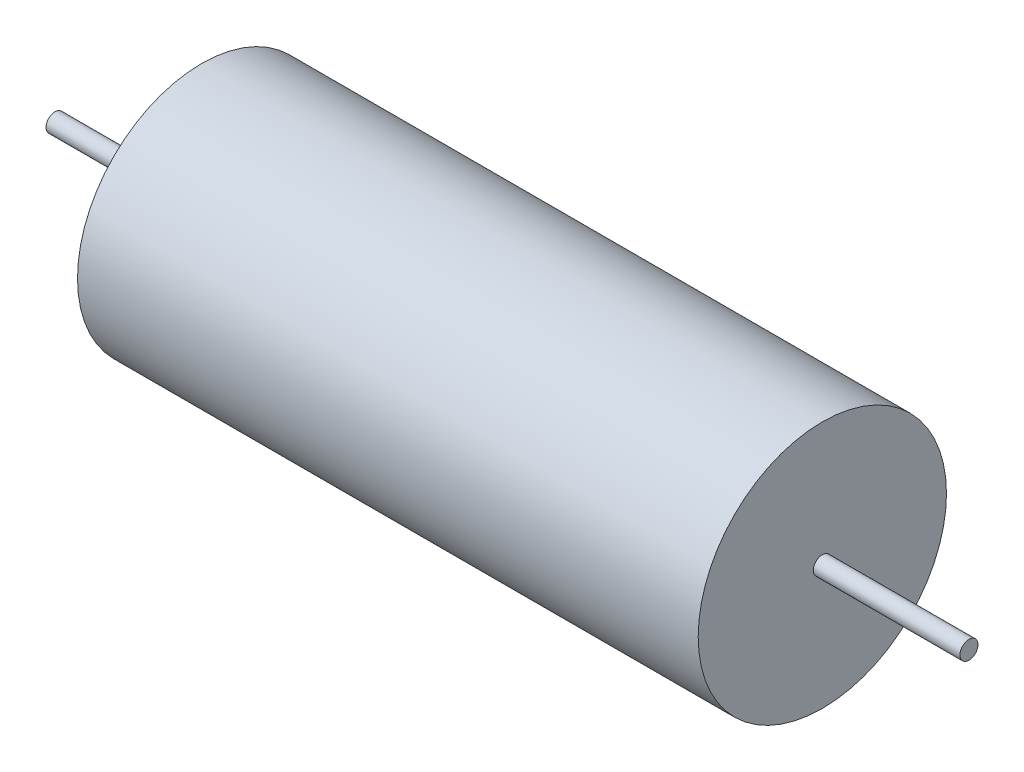
from build123d import *


with BuildPart() as part:
    # Sketch1 → Revolve1 (revolve)
    with BuildSketch(Plane.XY):
        Polygon((-93.5, 0), (-93.5, 1.85), (-63.5, 1.85), (-63.5, 25.4), (63.5, 25.4), (63.5, 1.85), (93.5, 1.85), (93.5, 0), align=None)
    revolve(axis=Axis((93.5, 0, 0), (-1, 0, 0)))


solid = part.part
